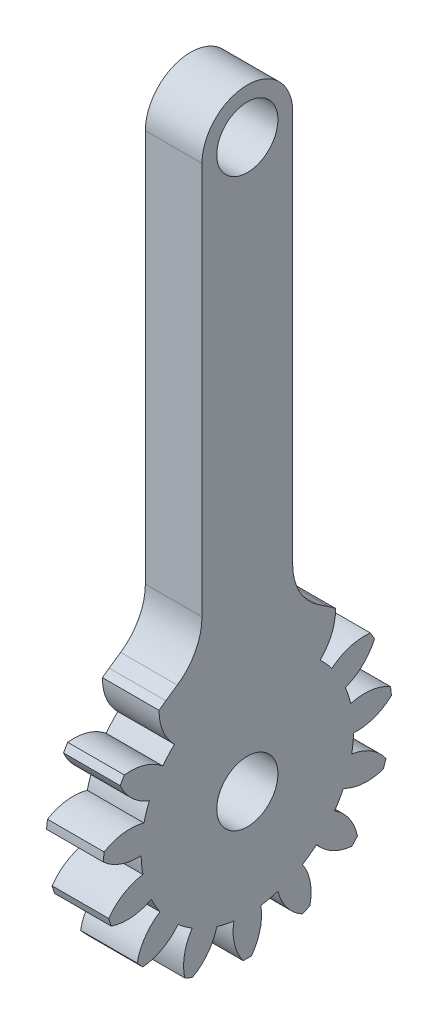
from build123d import *

# Parameters (mm, degrees)
BASPROSKE_W         = 5
BASPROSKE_H         = 12.75
TOOTHCUT_DEPTH      = 19.711627401
TEETHCUTS_COUNT     = 15
TEETHCUTS_ANGLE     = 336
BORSKE_R            = 2.7
BORE_DEPTH          = 50.0015748
SKETCH1_R           = 2.7
BOSS_EXTRUDE1_DEPTH = 5
FILLET1_R           = 5


with BuildPart() as part:
    # BasProSke → Base-Revolve (revolve)
    with BuildSketch(Plane(origin=(0, 0, 0), x_dir=(1, 0, 0), z_dir=(0, 1, 0)), mode=Mode.PRIVATE) as base_revolve_sk:
        with Locations((2.5, 6.375)):
            Rectangle(BASPROSKE_W, BASPROSKE_H)
    revolve(base_revolve_sk.sketch.rotate(Axis((-10, 0, 0), (1, 0, 0)), 180), axis=Axis((-10, 0, 0), (1, 0, 0)))

    # TooCutSke → ToothCut (cut, through all)
    with BuildSketch(Plane(origin=(0, 0, 0), x_dir=(0, 0, -1), z_dir=(1, 0, 0))):
        with BuildLine():
            ThreePointArc((0.769645606, 9.34235097), (0, 9.374), (-0.769645606, 9.34235097))
            ThreePointArc((-0.769645606, 9.34235097), (-1.209019537, 11.113083179), (-2.315283452, 12.563849239))
            ThreePointArc((-2.315283452, 12.563849239), (0, 12.7754), (2.315283452, 12.563849239))
            ThreePointArc((2.315283452, 12.563849239), (1.209019537, 11.113083179), (0.769645606, 9.34235097))
        make_face()
    toothcut = extrude(amount=TOOTHCUT_DEPTH, mode=Mode.SUBTRACT)

    # TeethCuts: ToothCut ×15 about axis
    teethcuts_axis = Axis((-10, 0, 0), (1, 0, 0))
    for i in range(1, TEETHCUTS_COUNT):
        add(toothcut.rotate(teethcuts_axis, i * TEETHCUTS_ANGLE / (TEETHCUTS_COUNT - 1)), mode=Mode.SUBTRACT)

    # BorSke → Bore (cut, symmetric)
    with BuildSketch(Plane(origin=(0, 0, 0), x_dir=(0, 0, -1), z_dir=(1, 0, 0))):
        with Locations(Location((0, 0, 0), (0, 0, 180))):
            Circle(BORSKE_R)
    extrude(amount=BORE_DEPTH, both=True, mode=Mode.SUBTRACT)

    # Sketch1 → Boss-Extrude1 (add)
    with BuildSketch(Plane.ZY):
        with BuildLine():
            Line((4, 12.709543162), (4, 50))
            ThreePointArc((4, 50), (0, 54), (-4, 50))
            Line((-4, 50), (-4, 12.709543162))
            Line((-4, 12.709543162), (-7.194322072, 10.526358816))
            Line((-7.194322072, 10.526358816), (-4.502982719, 8.221619222))
            Line((-4.502982719, 8.221619222), (4.502982719, 8.221619222))
            Line((4.502982719, 8.221619222), (7.194322072, 10.526358816))
            Line((7.194322072, 10.526358816), (4, 12.709543162))
        make_face()
        with Locations((0, 50)):
            Circle(SKETCH1_R, mode=Mode.SUBTRACT)
    extrude(amount=-BOSS_EXTRUDE1_DEPTH)

    # Fillet1
    fillet1_edges = [part.edges().sort_by_distance(p)[0] for p in [
        (2.5, 12.709543162, 4),
        (2.5, 12.709543162, -4),
    ]]
    fillet(fillet1_edges, radius=FILLET1_R)


solid = part.part
